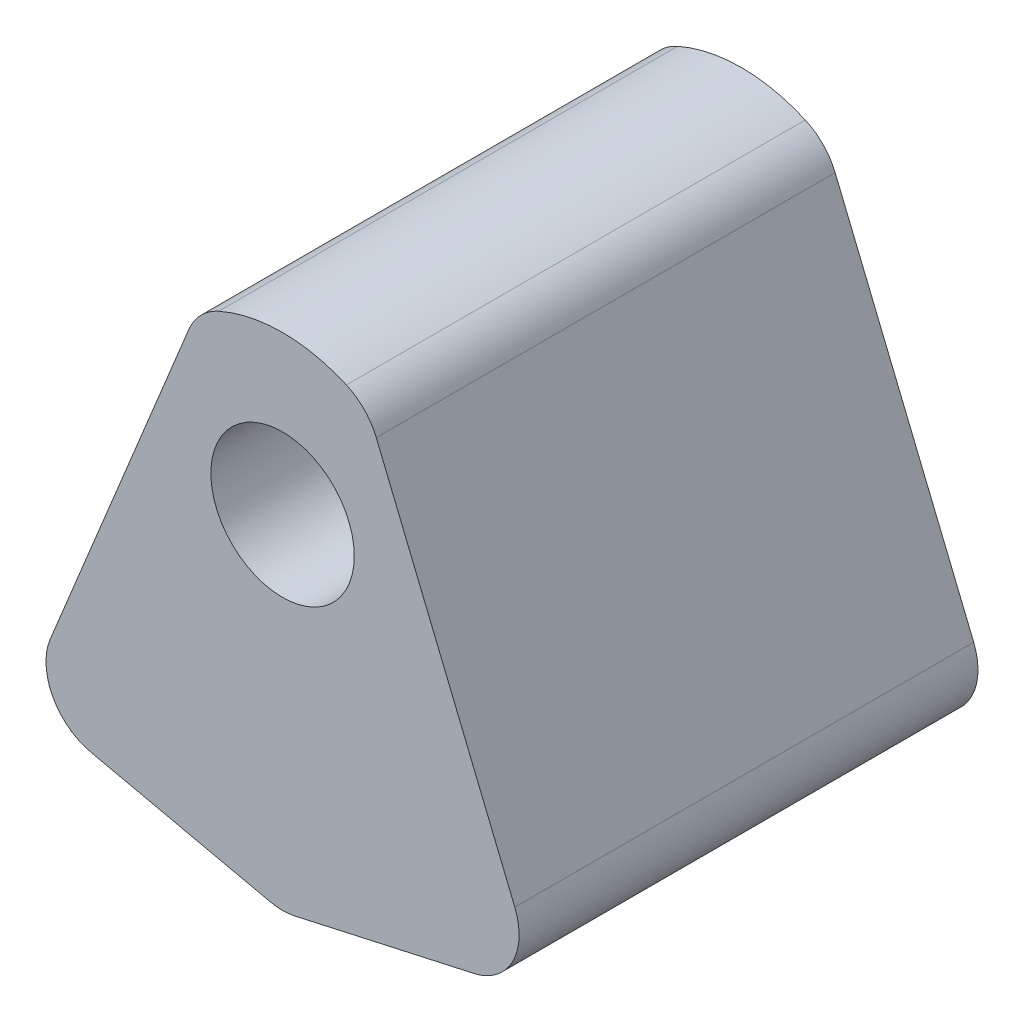
from build123d import *

# Parameters (mm, degrees)
SZKIC1_R                    = 1.25
DODANIE_WYCI_GNI_CIE1_DEPTH = 8


with BuildPart() as part:
    # Szkic1 → Dodanie-wyciągnięcie1 (new body)
    with BuildSketch(Plane.XY):
        with BuildLine():
            Line((0.216930458, 0.048206768), (3.340774171, 0.74239426))
            ThreePointArc((3.340774171, 0.74239426), (4.010273516, 1.255718269), (4.04887337, 2.098476219))
            Line((4.04887337, 2.098476219), (1.633372376, 7.980129441))
            ThreePointArc((1.633372376, 7.980129441), (1.424945236, 8.297716323), (1.113109988, 8.514654282))
            ThreePointArc((1.113109988, 8.514654282), (0, 8.75), (-1.113109988, 8.514654282))
            ThreePointArc((-1.113109988, 8.514654282), (-1.424945236, 8.297716323), (-1.633372376, 7.980129441))
            Line((-1.633372376, 7.980129441), (-4.04887337, 2.098476219))
            ThreePointArc((-4.04887337, 2.098476219), (-4.010273516, 1.255718269), (-3.340774171, 0.74239426))
            Line((-3.340774171, 0.74239426), (-0.216930458, 0.048206768))
            ThreePointArc((-0.216930458, 0.048206768), (0, 0.024393829), (0.216930458, 0.048206768))
        make_face()
        with Locations((0, 6)):
            Circle(SZKIC1_R, mode=Mode.SUBTRACT)
    extrude(amount=DODANIE_WYCI_GNI_CIE1_DEPTH)


solid = part.part
